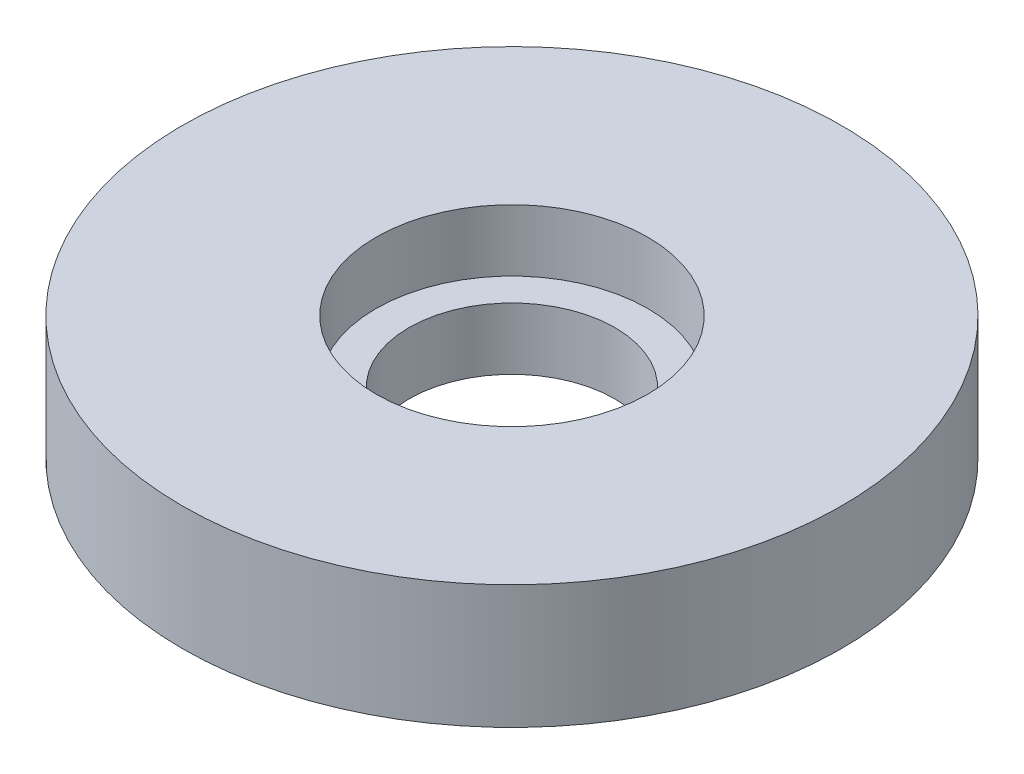
from build123d import *

# Parameters (mm, degrees)
SKETCH1_R           = 16
BOSS_EXTRUDE1_DEPTH = 6
SKETCH4_R           = 6.6
CUT_EXTRUDE2_DEPTH  = 3
SKETCH5_R           = 5
CUT_EXTRUDE3_DEPTH  = 3


with BuildPart() as part:
    # Sketch1 → Boss-Extrude1 (new body)
    with BuildSketch(Plane(origin=(0, 0, 0), x_dir=(1, 0, 0), z_dir=(0, 1, 0))):
        Circle(SKETCH1_R)
    extrude(amount=BOSS_EXTRUDE1_DEPTH)

    # Sketch4 → Cut-Extrude2 (cut)
    with BuildSketch(Plane(origin=(0, 6, 0), x_dir=(1, 0, 0), z_dir=(0, 1, 0))):
        Circle(SKETCH4_R)
    extrude(amount=-CUT_EXTRUDE2_DEPTH, mode=Mode.SUBTRACT)

    # Sketch5 → Cut-Extrude3 (cut)
    with BuildSketch(Plane(origin=(0, 0, 0), x_dir=(-1, 0, 0), z_dir=(0, -1, 0))):
        Circle(SKETCH5_R)
    extrude(amount=-CUT_EXTRUDE3_DEPTH, mode=Mode.SUBTRACT)


solid = part.part
